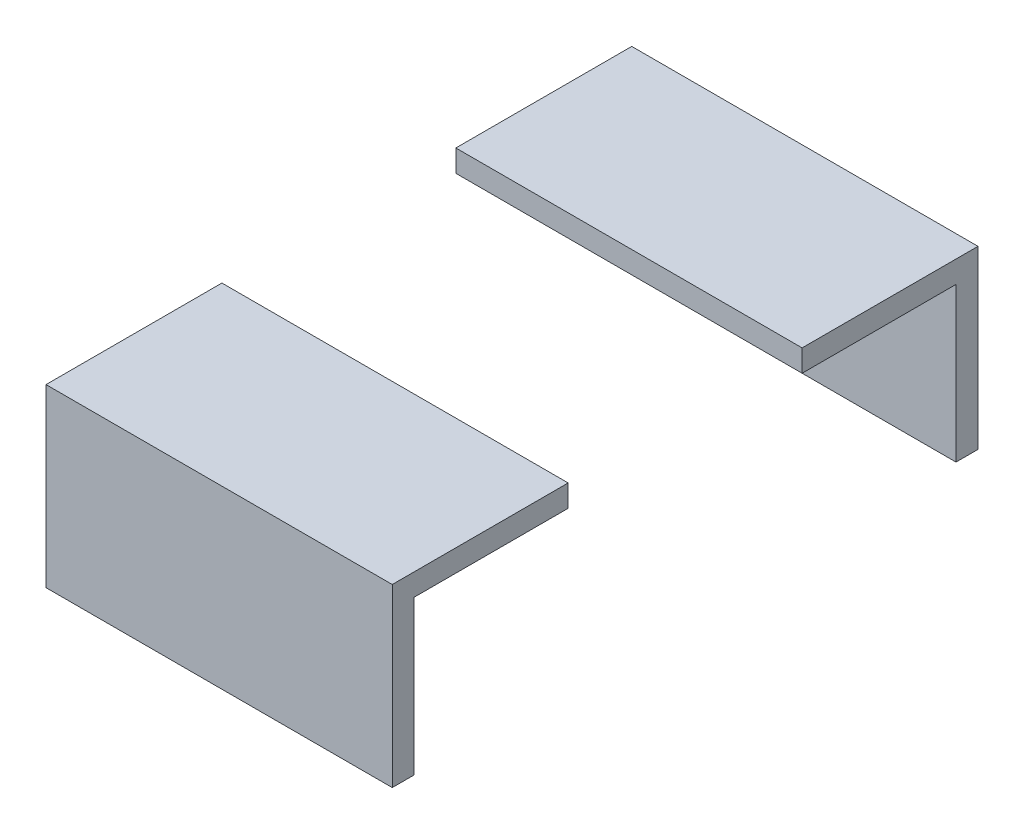
from build123d import *

# Parameters (mm, degrees)
BOSS_EXTRUDE1_DEPTH   = 12.5
BOSS_EXTRUDE1_2_DEPTH = 12.5


with BuildPart() as part:
    # Sketch2 → Boss-Extrude1 (new body, symmetric)
    with BuildSketch(Plane(origin=(0, 0, 0), x_dir=(0, 0, -1), z_dir=(1, 0, 0))):
        Polygon((8.4455, 3.75), (19.558, 3.75), (19.558, -7.3625), (21.1455, -7.3625), (21.1455, 5.3375), (8.4455, 5.3375), align=None)
    extrude(amount=BOSS_EXTRUDE1_DEPTH, both=True)


with BuildPart() as body_2:
    # Sketch2 → Boss-Extrude1 2 (new body, symmetric)
    with BuildSketch(Plane(origin=(0, 0, 0), x_dir=(0, 0, -1), z_dir=(1, 0, 0))):
        Polygon((-21.1455, 5.3375), (-21.1455, -7.3625), (-19.558, -7.3625), (-19.558, 3.75), (-8.4455, 3.75), (-8.4455, 5.3375), align=None)
    extrude(amount=BOSS_EXTRUDE1_2_DEPTH, both=True)


solid = Compound([part.part, body_2.part])
